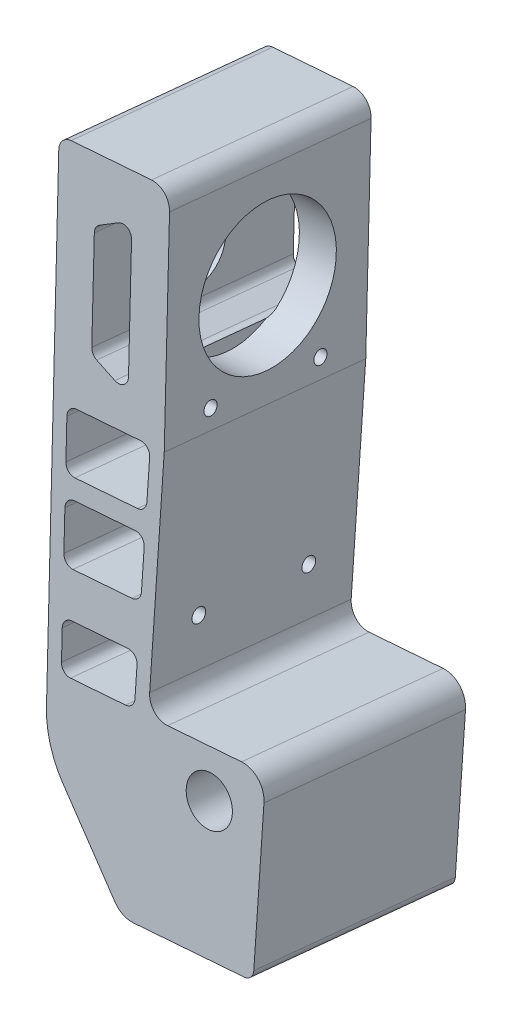
from build123d import *

# Parameters (mm, degrees)
SKETCH2_R           = 5
BOSS_EXTRUDE1_DEPTH = 44
SKETCH4_R           = 7
CUT_EXTRUDE1_DEPTH  = 44
SKETCH3_R           = 15
SKETCH3_R_2         = 1.432268471
SKETCH3_R_3         = 1.5
CUT_EXTRUDE2_DEPTH  = 8.5


with BuildPart() as part:
    # Sketch2 → Boss-Extrude1 (new body)
    with BuildSketch(Plane(origin=(0, 5.184806561, 52.754021043), x_dir=(1, 0, 0), z_dir=(0, 0.097811411, 0.995204968))):
        with BuildLine():
            Line((-79.338568196, 60.019636282), (-86.171283653, 157.182642502))
            ThreePointArc((-86.171283653, 157.182642502), (-85.540604549, 159.070011115), (-83.760075933, 159.958624788))
            Line((-83.760075933, 159.958624788), (-66.40294057, 161.179216572))
            ThreePointArc((-66.40294057, 161.179216572), (-63.499296447, 160.208940992), (-62.13219844, 157.469666101))
            Line((-62.13219844, 157.469666101), (-59.185942386, 115.573132123))
            Line((-59.185942386, 115.573132123), (-58.165469, 72.72467593))
            ThreePointArc((-58.165469, 72.72467593), (-56.858994047, 69.861695577), (-53.88600747, 68.829763352))
            Line((-53.88600747, 68.829763352), (-37.927916785, 69.95197125))
            ThreePointArc((-37.927916785, 69.95197125), (-34.211684563, 68.662057426), (-32.578589401, 65.083334219))
            Line((-32.578589401, 65.083334219), (-31.866862588, 35.198777134))
            ThreePointArc((-31.866862588, 35.198777134), (-32.387188107, 33.80496391), (-33.725997726, 33.156085835))
            Line((-33.725997726, 33.156085835), (-57.666874392, 31.472510939))
            ThreePointArc((-57.666874392, 31.472510939), (-59.969896102, 31.85708433), (-61.84718043, 33.245468007))
            Line((-61.84718043, 33.245468007), (-74.706082713, 48.563713079))
            ThreePointArc((-74.706082713, 48.563713079), (-77.929269747, 53.924929356), (-79.338568196, 60.019636282))
        make_face()
        with Locations((-43.960887699, 60.004258737)):
            Circle(SKETCH2_R, mode=Mode.SUBTRACT)
        with BuildLine():
            Line((-62.966135351, 68.191231545), (-74.842135577, 67.356085192))
            ThreePointArc((-74.842135577, 67.356085192), (-76.293957569, 67.841222959), (-76.97750654, 69.21086034))
            Line((-76.97750654, 69.21086034), (-77.398400264, 75.196079506))
            ThreePointArc((-77.398400264, 75.196079506), (-76.913262497, 76.647901499), (-75.543625116, 77.33145047))
            Line((-75.543625116, 77.33145047), (-63.389739784, 78.186138312))
            ThreePointArc((-63.389739784, 78.186138312), (-61.903246895, 77.670172783), (-61.25000883, 76.2386835))
            Line((-61.25000883, 76.2386835), (-61.107000214, 70.233922844))
            ThreePointArc((-61.107000214, 70.233922844), (-61.627325733, 68.84010962), (-62.966135351, 68.191231545))
        make_face(mode=Mode.SUBTRACT)
        with BuildLine():
            Line((-63.800352281, 103.21900204), (-77.297348966, 102.269863664))
            ThreePointArc((-77.297348966, 102.269863664), (-78.749170958, 102.755001431), (-79.43271993, 104.124638812))
            Line((-79.43271993, 104.124638812), (-79.993911561, 112.104931034))
            ThreePointArc((-79.993911561, 112.104931034), (-79.508773795, 113.556753027), (-78.139136414, 114.240301998))
            Line((-78.139136414, 114.240301998), (-64.271626252, 115.215495692))
            ThreePointArc((-64.271626252, 115.215495692), (-62.785133364, 114.699530163), (-62.131895299, 113.26804088))
            Line((-62.131895299, 113.26804088), (-61.941217144, 105.261693339))
            ThreePointArc((-61.941217144, 105.261693339), (-62.461542663, 103.867880114), (-63.800352281, 103.21900204))
        make_face(mode=Mode.SUBTRACT)
        with BuildLine():
            Line((-76.689803818, 136.396552471), (-77.391293358, 146.371917749))
            ThreePointArc((-77.391293358, 146.371917749), (-77.167089785, 147.441743104), (-76.413930361, 148.233920114))
            Line((-76.413930361, 148.233920114), (-72.564082157, 150.509588985))
            ThreePointArc((-72.564082157, 150.509588985), (-70.616844652, 150.558754011), (-69.551299044, 148.928182436))
            Line((-69.551299044, 148.928182436), (-68.709511596, 136.957744103))
            Line((-68.709511596, 136.957744103), (-67.867724148, 124.987305769))
            ThreePointArc((-67.867724148, 124.987305769), (-68.694580699, 123.223656329), (-70.629534734, 122.999817141))
            Line((-70.629534734, 122.999817141), (-74.759978753, 124.71429438))
            ThreePointArc((-74.759978753, 124.71429438), (-75.616592755, 125.393268596), (-75.988314278, 126.421187193))
            Line((-75.988314278, 126.421187193), (-76.689803818, 136.396552471))
        make_face(mode=Mode.SUBTRACT)
        with BuildLine():
            Line((-63.41899597, 87.206306956), (-76.174965702, 86.30927922))
            ThreePointArc((-76.174965702, 86.30927922), (-77.626787695, 86.794416987), (-78.310336666, 88.164054367))
            Line((-78.310336666, 88.164054367), (-78.871528298, 96.14434659))
            ThreePointArc((-78.871528298, 96.14434659), (-78.386390531, 97.596168582), (-77.01675315, 98.279717553))
            Line((-77.01675315, 98.279717553), (-63.890269942, 99.202800609))
            ThreePointArc((-63.890269942, 99.202800609), (-62.403777053, 98.68683508), (-61.750538988, 97.255345797))
            Line((-61.750538988, 97.255345797), (-61.559860833, 89.248998255))
            ThreePointArc((-61.559860833, 89.248998255), (-62.080186352, 87.855185031), (-63.41899597, 87.206306956))
        make_face(mode=Mode.SUBTRACT)
    extrude(amount=BOSS_EXTRUDE1_DEPTH)

    # Sketch4 → Cut-Extrude1 (cut)
    with BuildSketch(Plane(origin=(-74.74821025, -5.231253014, 0.514141565), x_dir=(0.006844627, 0.000479021, 0.999976461), z_dir=(-0.997536528, -0.069812587, 0.006861368))):
        with Locations((60.947145558, 147.088883585)):
            Circle(SKETCH4_R)
    extrude(amount=-CUT_EXTRUDE1_DEPTH, mode=Mode.SUBTRACT)

    # Sketch3 → Cut-Extrude2 (cut)
    with BuildSketch(Plane(origin=(-50.807333583, -3.555750914, 0.349468729), x_dir=(-0.006844627, -0.000479021, -0.999976461), z_dir=(0.997536528, 0.069812587, -0.006861368))):
        with Locations((-60.947145558, 147.088883585)):
            Circle(SKETCH3_R)
        with Locations((-74.548623077, 131.340873995)):
            Circle(SKETCH3_R_2)
        with Locations((-78.140713739, 94.702052828)):
            Circle(SKETCH3_R_3)
        with Locations((-54.255232262, 92.360306772)):
            Circle(SKETCH3_R_3)
        with Locations((-50.6631416, 128.999127938)):
            Circle(SKETCH3_R_2)
    extrude(amount=-CUT_EXTRUDE2_DEPTH, mode=Mode.SUBTRACT)


solid = part.part
